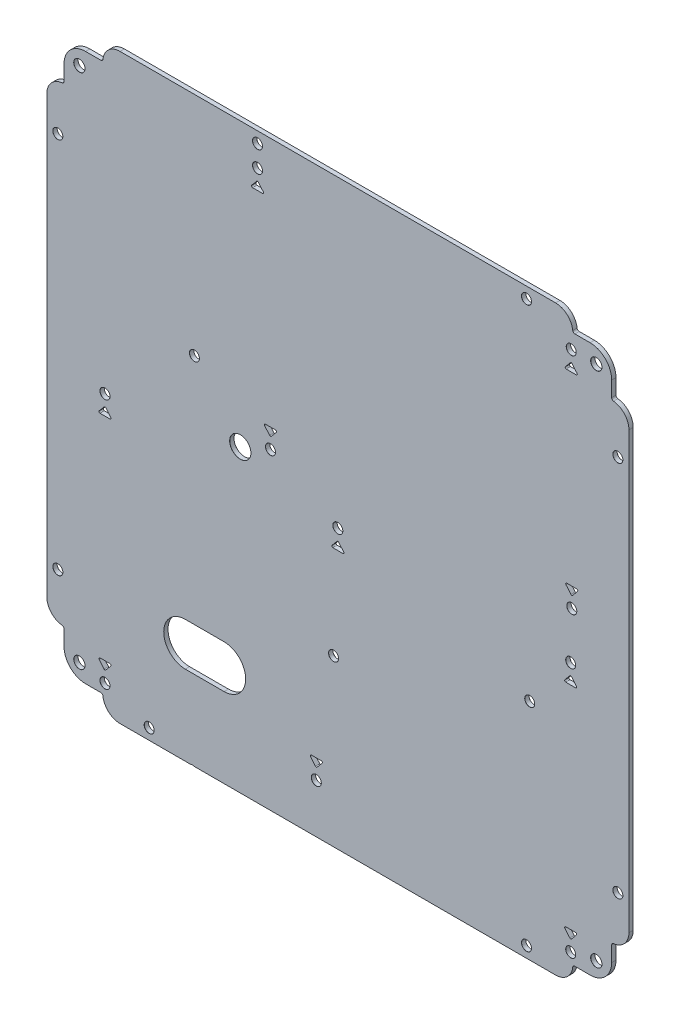
from build123d import *

# Parameters (mm, degrees)
SKETCH1_W                                = 270
SKETCH1_H                                = 270
BOSS_EXTRUDE1_DEPTH                      = 1
F_5_2_5_2_DIAMETER_HOLE1_AT_2_COUNT      = 2
F_5_2_5_2_DIAMETER_HOLE1_AT_2_PITCH      = 239.75
F_5_2_5_2_DIAMETER_HOLE1_AT_3_COUNT      = 2
F_5_2_5_2_DIAMETER_HOLE1_AT_3_PITCH      = 339.057701579
F_5_2_5_2_DIAMETER_HOLE1_AT_4_COUNT      = 2
F_5_2_5_2_DIAMETER_HOLE1_AT_4_PITCH      = 239.75
CUT_EXTRUDE1_DEPTH                       = 191.921449816
MIRROR1_AT_THE_SECOND_PLANE_COPY_1_DEPTH = 191.921449816
F_4_6_4_6_DIAMETER_HOLE1_AT_2_COUNT      = 2
F_4_6_4_6_DIAMETER_HOLE1_AT_2_PITCH      = 175
F_4_6_4_6_DIAMETER_HOLE1_AT_3_COUNT      = 2
F_4_6_4_6_DIAMETER_HOLE1_AT_3_PITCH      = 313.201313056
F_4_6_4_6_DIAMETER_HOLE1_AT_4_COUNT      = 2
F_4_6_4_6_DIAMETER_HOLE1_AT_4_PITCH      = 259.75
F_4_6_4_6_DIAMETER_HOLE1_AT_5_COUNT      = 2
F_4_6_4_6_DIAMETER_HOLE1_AT_5_PITCH      = 307.414673121
F_4_6_4_6_DIAMETER_HOLE1_AT_6_COUNT      = 2
F_4_6_4_6_DIAMETER_HOLE1_AT_6_PITCH      = 221.466772338
F_4_6_4_6_DIAMETER_HOLE1_AT_7_COUNT      = 2
F_4_6_4_6_DIAMETER_HOLE1_AT_7_PITCH      = 59.927299706
F_4_6_4_6_DIAMETER_HOLE1_AT_8_COUNT      = 2
F_4_6_4_6_DIAMETER_HOLE1_AT_8_PITCH      = 172.413474676
CUT_EXTRUDE2_DEPTH                       = 191.921449816
CUT_EXTRUDE2_DEPTH_BACK                  = 191.921449816
F_4_6_4_6_DIAMETER_HOLE2_AT_2_COUNT      = 2
F_4_6_4_6_DIAMETER_HOLE2_AT_2_PITCH      = 145.5
F_4_6_4_6_DIAMETER_HOLE2_AT_3_COUNT      = 2
F_4_6_4_6_DIAMETER_HOLE2_AT_3_PITCH      = 110.163514831
F_4_6_4_6_DIAMETER_HOLE2_AT_4_COUNT      = 2
F_4_6_4_6_DIAMETER_HOLE2_AT_4_PITCH      = 179.050446802
F_4_6_4_6_DIAMETER_HOLE2_AT_5_COUNT      = 2
F_4_6_4_6_DIAMETER_HOLE2_AT_5_PITCH      = 258.951625815
F_4_6_4_6_DIAMETER_HOLE3_AT_2_COUNT      = 2
F_4_6_4_6_DIAMETER_HOLE3_AT_2_PITCH      = 108
F_4_6_4_6_DIAMETER_HOLE3_AT_3_COUNT      = 2
F_4_6_4_6_DIAMETER_HOLE3_AT_3_PITCH      = 216
F_4_6_4_6_DIAMETER_HOLE3_AT_4_COUNT      = 2
F_4_6_4_6_DIAMETER_HOLE3_AT_4_PITCH      = 116.25
F_4_6_4_6_DIAMETER_HOLE3_AT_5_COUNT      = 2
F_4_6_4_6_DIAMETER_HOLE3_AT_5_PITCH      = 144.544327111
F_4_6_4_6_DIAMETER_HOLE3_AT_6_COUNT      = 2
F_4_6_4_6_DIAMETER_HOLE3_AT_6_PITCH      = 245.295867271
CUT_EXTRUDE3_DEPTH                       = 191.921449816
CUT_EXTRUDE4_DEPTH                       = 191.921449816
F_4_6_4_6_DIAMETER_HOLE4_AT_2_COUNT      = 2
F_4_6_4_6_DIAMETER_HOLE4_AT_2_PITCH      = 109.308336828
F_4_6_4_6_DIAMETER_HOLE4_AT_3_COUNT      = 2
F_4_6_4_6_DIAMETER_HOLE4_AT_3_PITCH      = 167.03667262


with BuildPart() as part:
    # Sketch1 → Boss-Extrude1 (new, symmetric)
    with BuildSketch(Plane.XY):
        Rectangle(SKETCH1_W, SKETCH1_H)
    extrude(amount=BOSS_EXTRUDE1_DEPTH, both=True)

    # Sketch11 → Ø5.2 (5.2) Diameter Hole1 (revolve, cut)
    with BuildSketch(Plane(origin=(119.875, 119.875, 1), x_dir=(0, -1, 0), z_dir=(1, 0, 0))):
        Polygon((0, 0), (0, 2), (2.625, 2), (2.6, 1.975), (2.6, 0.025), (2.625, 0), align=None)
    f_5_2_5_2_diameter_hole1 = revolve(axis=Axis((119.875, 119.875, 7.35), (0, 0, -1)), mode=Mode.SUBTRACT)

    # Ø5.2 (5.2) Diameter Hole1 at 2: Ø5.2 (5.2) Diameter Hole1 ×2
    with Locations(*[(0, -i * F_5_2_5_2_DIAMETER_HOLE1_AT_2_PITCH, 0) for i in range(1, F_5_2_5_2_DIAMETER_HOLE1_AT_2_COUNT)]):
        add(f_5_2_5_2_diameter_hole1, mode=Mode.SUBTRACT)

    # Ø5.2 (5.2) Diameter Hole1 at 3: Ø5.2 (5.2) Diameter Hole1 ×2
    with Locations(*[Vector(-0.7071067811865476, -0.7071067811865476, 0) * (i * F_5_2_5_2_DIAMETER_HOLE1_AT_3_PITCH) for i in range(1, F_5_2_5_2_DIAMETER_HOLE1_AT_3_COUNT)]):
        add(f_5_2_5_2_diameter_hole1, mode=Mode.SUBTRACT)

    # Ø5.2 (5.2) Diameter Hole1 at 4: Ø5.2 (5.2) Diameter Hole1 ×2
    with Locations(*[(-i * F_5_2_5_2_DIAMETER_HOLE1_AT_4_PITCH, 0, 0) for i in range(1, F_5_2_5_2_DIAMETER_HOLE1_AT_4_COUNT)]):
        add(f_5_2_5_2_diameter_hole1, mode=Mode.SUBTRACT)

    # Sketch12 → Cut-Extrude1 (cut, symmetric)
    with BuildSketch(Plane.XY):
        with BuildLine():
            Line((-127, 109.94427191), (-127, 117))
            ThreePointArc((-127, 117), (-124.071067812, 124.071067812), (-117, 127))
            Line((-117, 127), (-109.94427191, 127))
            ThreePointArc((-109.94427191, 127), (-109.277605243, 127.254644008), (-108.95046392, 127.888888889))
            ThreePointArc((-108.95046392, 127.888888889), (-106.333333333, 132.96284794), (-101, 135))
            Line((-101, 135), (-135, 135))
            Line((-135, 135), (-135, 101))
            ThreePointArc((-135, 101), (-132.96284794, 106.333333333), (-127.888888889, 108.95046392))
            ThreePointArc((-127.888888889, 108.95046392), (-127.254644008, 109.277605243), (-127, 109.94427191))
        make_face()
    cut_extrude1 = extrude(amount=CUT_EXTRUDE1_DEPTH, both=True, mode=Mode.SUBTRACT)

    # Mirror1: Cut-Extrude1 across plane
    add(cut_extrude1.mirror(Plane(origin=(0, 0, 0), x_dir=(0, 0, 1), z_dir=(1, 0, 0))), mode=Mode.SUBTRACT)

    # Mirror1 at the second plane: Cut-Extrude1 across plane
    add(cut_extrude1.mirror(Plane.ZX), mode=Mode.SUBTRACT)

    # Mirror1 at the second plane copy 1 sketc → Mirror1 at the second plane copy 1 (cut, symmetric)
    with BuildSketch(Plane(origin=(0, 0, 0), x_dir=(-1, 0, 0), z_dir=(0, 0, 1))):
        with BuildLine():
            Line((-127, 109.94427191), (-127, 117))
            ThreePointArc((-127, 117), (-124.071067812, 124.071067812), (-117, 127))
            Line((-117, 127), (-109.94427191, 127))
            ThreePointArc((-109.94427191, 127), (-109.277605243, 127.254644008), (-108.95046392, 127.888888889))
            ThreePointArc((-108.95046392, 127.888888889), (-106.333333333, 132.96284794), (-101, 135))
            Line((-101, 135), (-135, 135))
            Line((-135, 135), (-135, 101))
            ThreePointArc((-135, 101), (-132.96284794, 106.333333333), (-127.888888889, 108.95046392))
            ThreePointArc((-127.888888889, 108.95046392), (-127.254644008, 109.277605243), (-127, 109.94427191))
        make_face()
    extrude(amount=MIRROR1_AT_THE_SECOND_PLANE_COPY_1_DEPTH, both=True, mode=Mode.SUBTRACT)

    # Sketch15 → Ø4.6 (4.6) Diameter Hole1 (revolve, cut)
    with BuildSketch(Plane(origin=(129.875, 87.5, 1), x_dir=(0, -1, 0), z_dir=(1, 0, 0))):
        Polygon((0, 0), (0, 2), (2.325, 2), (2.3, 1.975), (2.3, 0.025), (2.325, 0), align=None)
    f_4_6_4_6_diameter_hole1 = revolve(axis=Axis((129.875, 87.5, 7.35), (0, 0, -1)), mode=Mode.SUBTRACT)

    # Ø4.6 (4.6) Diameter Hole1 at 2: Ø4.6 (4.6) Diameter Hole1 ×2
    with Locations(*[(0, -i * F_4_6_4_6_DIAMETER_HOLE1_AT_2_PITCH, 0) for i in range(1, F_4_6_4_6_DIAMETER_HOLE1_AT_2_COUNT)]):
        add(f_4_6_4_6_diameter_hole1, mode=Mode.SUBTRACT)

    # Ø4.6 (4.6) Diameter Hole1 at 3: Ø4.6 (4.6) Diameter Hole1 ×2
    with Locations(*[Vector(-0.8293387963975757, -0.5587460610955756, 0) * (i * F_4_6_4_6_DIAMETER_HOLE1_AT_3_PITCH) for i in range(1, F_4_6_4_6_DIAMETER_HOLE1_AT_3_COUNT)]):
        add(f_4_6_4_6_diameter_hole1, mode=Mode.SUBTRACT)

    # Ø4.6 (4.6) Diameter Hole1 at 4: Ø4.6 (4.6) Diameter Hole1 ×2
    with Locations(*[(-i * F_4_6_4_6_DIAMETER_HOLE1_AT_4_PITCH, 0, 0) for i in range(1, F_4_6_4_6_DIAMETER_HOLE1_AT_4_COUNT)]):
        add(f_4_6_4_6_diameter_hole1, mode=Mode.SUBTRACT)

    # Ø4.6 (4.6) Diameter Hole1 at 5: Ø4.6 (4.6) Diameter Hole1 ×2
    with Locations(*[Vector(-0.7071067811865477, -0.7071067811865475, 0) * (i * F_4_6_4_6_DIAMETER_HOLE1_AT_5_PITCH) for i in range(1, F_4_6_4_6_DIAMETER_HOLE1_AT_5_COUNT)]):
        add(f_4_6_4_6_diameter_hole1, mode=Mode.SUBTRACT)

    # Ø4.6 (4.6) Diameter Hole1 at 6: Ø4.6 (4.6) Diameter Hole1 ×2
    with Locations(*[Vector(-0.19133795807186105, -0.9815242155957696, 0) * (i * F_4_6_4_6_DIAMETER_HOLE1_AT_6_PITCH) for i in range(1, F_4_6_4_6_DIAMETER_HOLE1_AT_6_COUNT)]):
        add(f_4_6_4_6_diameter_hole1, mode=Mode.SUBTRACT)

    # Ø4.6 (4.6) Diameter Hole1 at 7: Ø4.6 (4.6) Diameter Hole1 ×2
    with Locations(*[Vector(-0.7071067811865481, 0.7071067811865469, 0) * (i * F_4_6_4_6_DIAMETER_HOLE1_AT_7_PITCH) for i in range(1, F_4_6_4_6_DIAMETER_HOLE1_AT_7_COUNT)]):
        add(f_4_6_4_6_diameter_hole1, mode=Mode.SUBTRACT)

    # Ø4.6 (4.6) Diameter Hole1 at 8: Ø4.6 (4.6) Diameter Hole1 ×2
    with Locations(*[Vector(-0.9693267902270689, 0.2457754539169606, 0) * (i * F_4_6_4_6_DIAMETER_HOLE1_AT_8_PITCH) for i in range(1, F_4_6_4_6_DIAMETER_HOLE1_AT_8_COUNT)]):
        add(f_4_6_4_6_diameter_hole1, mode=Mode.SUBTRACT)

    # Sketch17 → Cut-Extrude2 (cut, two sides)
    with BuildSketch(Plane.XY) as cut_extrude2_sk:
        with BuildLine():
            Line((-70.75, -78), (-52.75, -78))
            ThreePointArc((-52.75, -78), (-42.75, -88), (-52.75, -98))
            Line((-52.75, -98), (-70.75, -98))
            ThreePointArc((-70.75, -98), (-80.75, -88), (-70.75, -78))
        make_face()
    extrude(amount=CUT_EXTRUDE2_DEPTH, mode=Mode.SUBTRACT)
    extrude(cut_extrude2_sk.sketch, amount=-CUT_EXTRUDE2_DEPTH_BACK, mode=Mode.SUBTRACT)

    # Sketch19 → Ø9.8 (9.8) Diameter Hole1 (revolve, cut)
    with BuildSketch(Plane(origin=(-45.25, 4, 1), x_dir=(0, -1, 0), z_dir=(1, 0, 0))):
        Polygon((0, 0), (0, 2), (4.925, 2), (4.9, 1.975), (4.9, 0.025), (4.925, 0), align=None)
    revolve(axis=Axis((-45.25, 4, 7.35), (0, 0, -1)), mode=Mode.SUBTRACT)

    # Sketch23 → Ø4.6 (4.6) Diameter Hole2 (revolve, cut)
    with BuildSketch(Plane(origin=(-37.25, 120, 1), x_dir=(0, -1, 0), z_dir=(1, 0, 0))):
        Polygon((0, 0), (0, 2), (2.325, 2), (2.3, 1.975), (2.3, 0.025), (2.325, 0), align=None)
    f_4_6_4_6_diameter_hole2 = revolve(axis=Axis((-37.25, 120, 7.35), (0, 0, -1)), mode=Mode.SUBTRACT)

    # Ø4.6 (4.6) Diameter Hole2 at 2: Ø4.6 (4.6) Diameter Hole2 ×2
    with Locations(*[Vector(0.9999996309679177, -0.0008591065292096222, 0) * (i * F_4_6_4_6_DIAMETER_HOLE2_AT_2_PITCH) for i in range(1, F_4_6_4_6_DIAMETER_HOLE2_AT_2_COUNT)]):
        add(f_4_6_4_6_diameter_hole2, mode=Mode.SUBTRACT)

    # Ø4.6 (4.6) Diameter Hole2 at 3: Ø4.6 (4.6) Diameter Hole2 ×2
    with Locations(*[Vector(0.054464493159869856, -0.9985157079309461, 0) * (i * F_4_6_4_6_DIAMETER_HOLE2_AT_3_PITCH) for i in range(1, F_4_6_4_6_DIAMETER_HOLE2_AT_3_COUNT)]):
        add(f_4_6_4_6_diameter_hole2, mode=Mode.SUBTRACT)

    # Ø4.6 (4.6) Diameter Hole2 at 4: Ø4.6 (4.6) Diameter Hole2 ×2
    with Locations(*[Vector(0.8140163993065361, -0.5808418904142694, 0) * (i * F_4_6_4_6_DIAMETER_HOLE2_AT_4_PITCH) for i in range(1, F_4_6_4_6_DIAMETER_HOLE2_AT_4_COUNT)]):
        add(f_4_6_4_6_diameter_hole2, mode=Mode.SUBTRACT)

    # Ø4.6 (4.6) Diameter Hole2 at 5: Ø4.6 (4.6) Diameter Hole2 ×2
    with Locations(*[Vector(-0.11666908977326872, -0.9931708430534382, 0) * (i * F_4_6_4_6_DIAMETER_HOLE2_AT_5_PITCH) for i in range(1, F_4_6_4_6_DIAMETER_HOLE2_AT_5_COUNT)]):
        add(f_4_6_4_6_diameter_hole2, mode=Mode.SUBTRACT)

    # Sketch26 → Ø4.6 (4.6) Diameter Hole3 (revolve, cut)
    with BuildSketch(Plane(origin=(-108, -6, 1), x_dir=(0, -1, 0), z_dir=(1, 0, 0))):
        Polygon((0, 0), (0, 2), (2.325, 2), (2.3, 1.975), (2.3, 0.025), (2.325, 0), align=None)
    f_4_6_4_6_diameter_hole3 = revolve(axis=Axis((-108, -6, 7.35), (0, 0, -1)), mode=Mode.SUBTRACT)

    # Ø4.6 (4.6) Diameter Hole3 at 2: Ø4.6 (4.6) Diameter Hole3 ×2
    with Locations(*[(i * F_4_6_4_6_DIAMETER_HOLE3_AT_2_PITCH, 0, 0) for i in range(1, F_4_6_4_6_DIAMETER_HOLE3_AT_2_COUNT)]):
        add(f_4_6_4_6_diameter_hole3, mode=Mode.SUBTRACT)

    # Ø4.6 (4.6) Diameter Hole3 at 3: Ø4.6 (4.6) Diameter Hole3 ×2
    with Locations(*[(i * F_4_6_4_6_DIAMETER_HOLE3_AT_3_PITCH, 0, 0) for i in range(1, F_4_6_4_6_DIAMETER_HOLE3_AT_3_COUNT)]):
        add(f_4_6_4_6_diameter_hole3, mode=Mode.SUBTRACT)

    # Ø4.6 (4.6) Diameter Hole3 at 4: Ø4.6 (4.6) Diameter Hole3 ×2
    with Locations(*[(0, -i * F_4_6_4_6_DIAMETER_HOLE3_AT_4_PITCH, 0) for i in range(1, F_4_6_4_6_DIAMETER_HOLE3_AT_4_COUNT)]):
        add(f_4_6_4_6_diameter_hole3, mode=Mode.SUBTRACT)

    # Ø4.6 (4.6) Diameter Hole3 at 5: Ø4.6 (4.6) Diameter Hole3 ×2
    with Locations(*[Vector(0.6779927096320881, -0.7350686265143813, 0) * (i * F_4_6_4_6_DIAMETER_HOLE3_AT_5_PITCH) for i in range(1, F_4_6_4_6_DIAMETER_HOLE3_AT_5_COUNT)]):
        add(f_4_6_4_6_diameter_hole3, mode=Mode.SUBTRACT)

    # Ø4.6 (4.6) Diameter Hole3 at 6: Ø4.6 (4.6) Diameter Hole3 ×2
    with Locations(*[Vector(0.8805692586813223, -0.47391748297085057, 0) * (i * F_4_6_4_6_DIAMETER_HOLE3_AT_6_PITCH) for i in range(1, F_4_6_4_6_DIAMETER_HOLE3_AT_6_COUNT)]):
        add(f_4_6_4_6_diameter_hole3, mode=Mode.SUBTRACT)

    # Sketch27 → Cut-Extrude3 (cut, symmetric)
    with BuildSketch(Plane.XY):
        with BuildLine():
            Line((-39.548924331, 111), (-34.951075669, 111))
            ThreePointArc((-34.951075669, 111), (-34.497634529, 111.289307967), (-34.568929927, 111.82243547))
            Line((-34.568929927, 111.82243547), (-36.867854258, 114.547086528))
            ThreePointArc((-36.867854258, 114.547086528), (-37.25, 114.724651059), (-37.632145742, 114.547086528))
            Line((-37.632145742, 114.547086528), (-39.931070073, 111.82243547))
            ThreePointArc((-39.931070073, 111.82243547), (-40.002365471, 111.289307967), (-39.548924331, 111))
        make_face()
    cut_extrude3 = extrude(amount=CUT_EXTRUDE3_DEPTH, both=True, mode=Mode.SUBTRACT)

    # Sketch-Pattern1: Cut-Extrude3 at 4 more places
    with Locations((145.499946, -0.125, 0), (145.25, -126, 0), (37.25, -126, 0), (-70.75, -126, 0)):
        add(cut_extrude3, mode=Mode.SUBTRACT)

    # Sketch29 → Cut-Extrude4 (cut, symmetric)
    with BuildSketch(Plane.XY):
        with BuildLine():
            Line((-33.548924331, 19), (-28.951075669, 19))
            ThreePointArc((-28.951075669, 19), (-28.497634529, 18.710692033), (-28.568929927, 18.17756453))
            Line((-28.568929927, 18.17756453), (-30.867854258, 15.452913472))
            ThreePointArc((-30.867854258, 15.452913472), (-31.25, 15.275348941), (-31.632145742, 15.452913472))
            Line((-31.632145742, 15.452913472), (-33.931070073, 18.17756453))
            ThreePointArc((-33.931070073, 18.17756453), (-34.002365471, 18.710692033), (-33.548924331, 19))
        make_face()
    cut_extrude4 = extrude(amount=CUT_EXTRUDE4_DEPTH, both=True, mode=Mode.SUBTRACT)

    # Sketch-Pattern2: Cut-Extrude4 at 4 more places
    with Locations((139.75, 6, 0), (139.25, -132.25, 0), (21.25, -122.25, 0), (-76.75, -132.25, 0)):
        add(cut_extrude4, mode=Mode.SUBTRACT)

    # Sketch32 → Ø4.6 (4.6) Diameter Hole4 (revolve, cut)
    with BuildSketch(Plane(origin=(-66.5, 30, 1), x_dir=(0, -1, 0), z_dir=(1, 0, 0))):
        Polygon((0, 0), (0, 2), (2.325, 2), (2.3, 1.975), (2.3, 0.025), (2.325, 0), align=None)
    f_4_6_4_6_diameter_hole4 = revolve(axis=Axis((-66.5, 30, 7.35), (0, 0, -1)), mode=Mode.SUBTRACT)

    # Ø4.6 (4.6) Diameter Hole4 at 2: Ø4.6 (4.6) Diameter Hole4 ×2
    with Locations(*[Vector(0.590073930973555, -0.80734921563436, 0) * (i * F_4_6_4_6_DIAMETER_HOLE4_AT_2_PITCH) for i in range(1, F_4_6_4_6_DIAMETER_HOLE4_AT_2_COUNT)]):
        add(f_4_6_4_6_diameter_hole4, mode=Mode.SUBTRACT)

    # Ø4.6 (4.6) Diameter Hole4 at 3: Ø4.6 (4.6) Diameter Hole4 ×2
    with Locations(*[Vector(0.9309332948318848, -0.36518926678292596, 0) * (i * F_4_6_4_6_DIAMETER_HOLE4_AT_3_PITCH) for i in range(1, F_4_6_4_6_DIAMETER_HOLE4_AT_3_COUNT)]):
        add(f_4_6_4_6_diameter_hole4, mode=Mode.SUBTRACT)


solid = part.part
